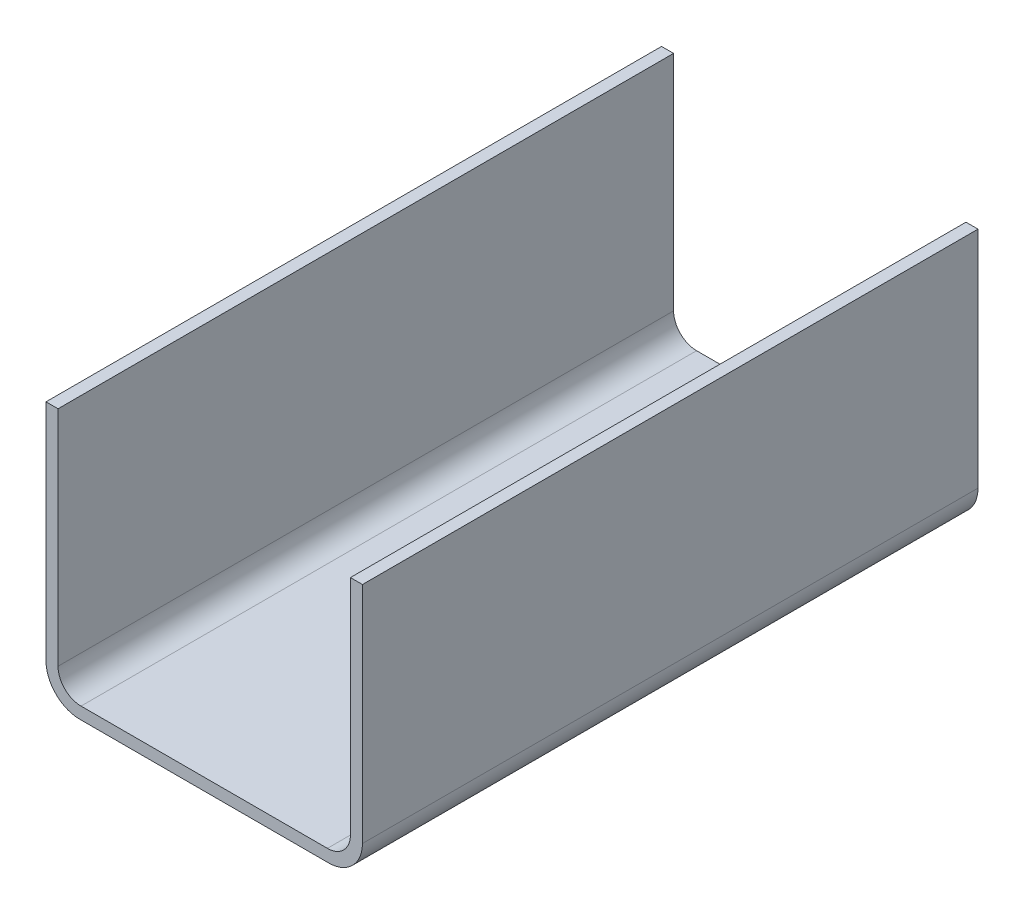
from build123d import *

# Parameters (mm, degrees)
BOSS_EXTRUDE1_DEPTH = 401.5
FILLET2_R           = 15
FILLET4_R           = 22


with BuildPart() as part:
    # Sketch1 → Boss-Extrude1 (new body)
    with BuildSketch(Plane.XY):
        Polygon((-95.35, 84.15), (-95.35, -76.3), (95.35, -76.3), (95.35, 84.15), (103.2, 84.15), (103.2, -84.15), (-103.2, -84.15), (-103.2, 84.15), align=None)
    extrude(amount=BOSS_EXTRUDE1_DEPTH)

    # Fillet2
    fillet2_edges = [part.edges().sort_by_distance(p)[0] for p in [
        (-95.35, -76.3, 200.75),
        (95.35, -76.3, 200.75),
    ]]
    fillet(fillet2_edges, radius=FILLET2_R)

    # Fillet4
    fillet4_edges = [part.edges().sort_by_distance(p)[0] for p in [
        (103.2, -84.15, 200.75),
        (-103.2, -84.15, 200.75),
    ]]
    fillet(fillet4_edges, radius=FILLET4_R)


solid = part.part
